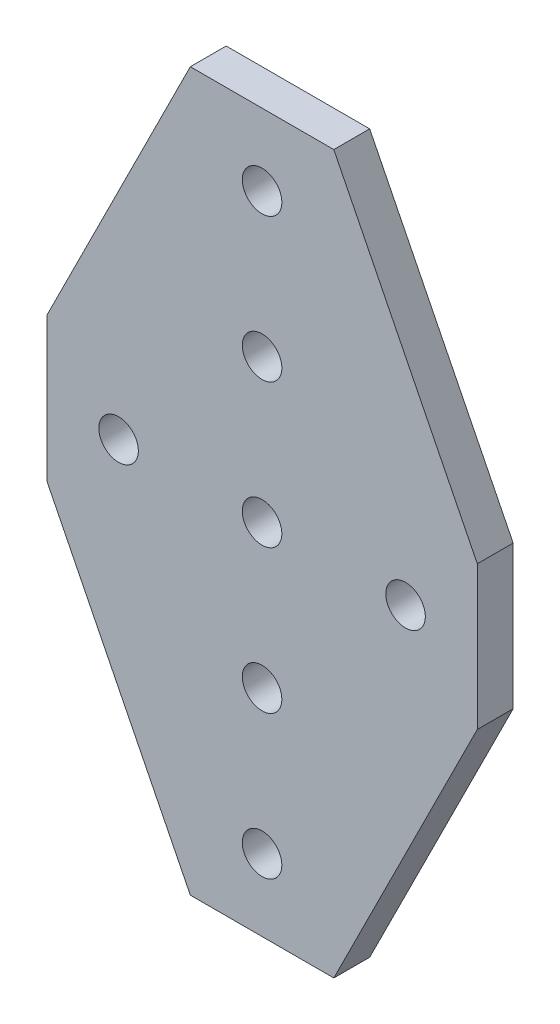
from build123d import *

# Parameters (mm, degrees)
BOSS_EXTRUDE1_DEPTH = 6.35
SKETCH2_R           = 3.5
CUT_EXTRUDE1_DEPTH  = 7.35


with BuildPart() as part:
    # Sketch1 → Boss-Extrude1 (new body)
    with BuildSketch(Plane.XY):
        Polygon((-25.4, 50.8), (-25.4, 76.2), (0, 127), (25.4, 127), (50.8, 76.2), (50.8, 50.8), (25.4, 0), (0, 0), align=None)
    extrude(amount=BOSS_EXTRUDE1_DEPTH)

    # Sketch2 → Cut-Extrude1 (cut, through all)
    with BuildSketch(Plane.XY.offset(6.35)):
        with Locations((12.7, 63.5)):
            Circle(SKETCH2_R)
        with Locations((38.1, 63.5)):
            Circle(SKETCH2_R)
        with Locations((-12.7, 63.5)):
            Circle(SKETCH2_R)
        with Locations((12.7, 38.1)):
            Circle(SKETCH2_R)
        with Locations((12.7, 12.7)):
            Circle(SKETCH2_R)
        with Locations((12.7, 114.3)):
            Circle(SKETCH2_R)
        with Locations((12.7, 88.9)):
            Circle(SKETCH2_R)
    extrude(amount=-CUT_EXTRUDE1_DEPTH, mode=Mode.SUBTRACT)


solid = part.part
